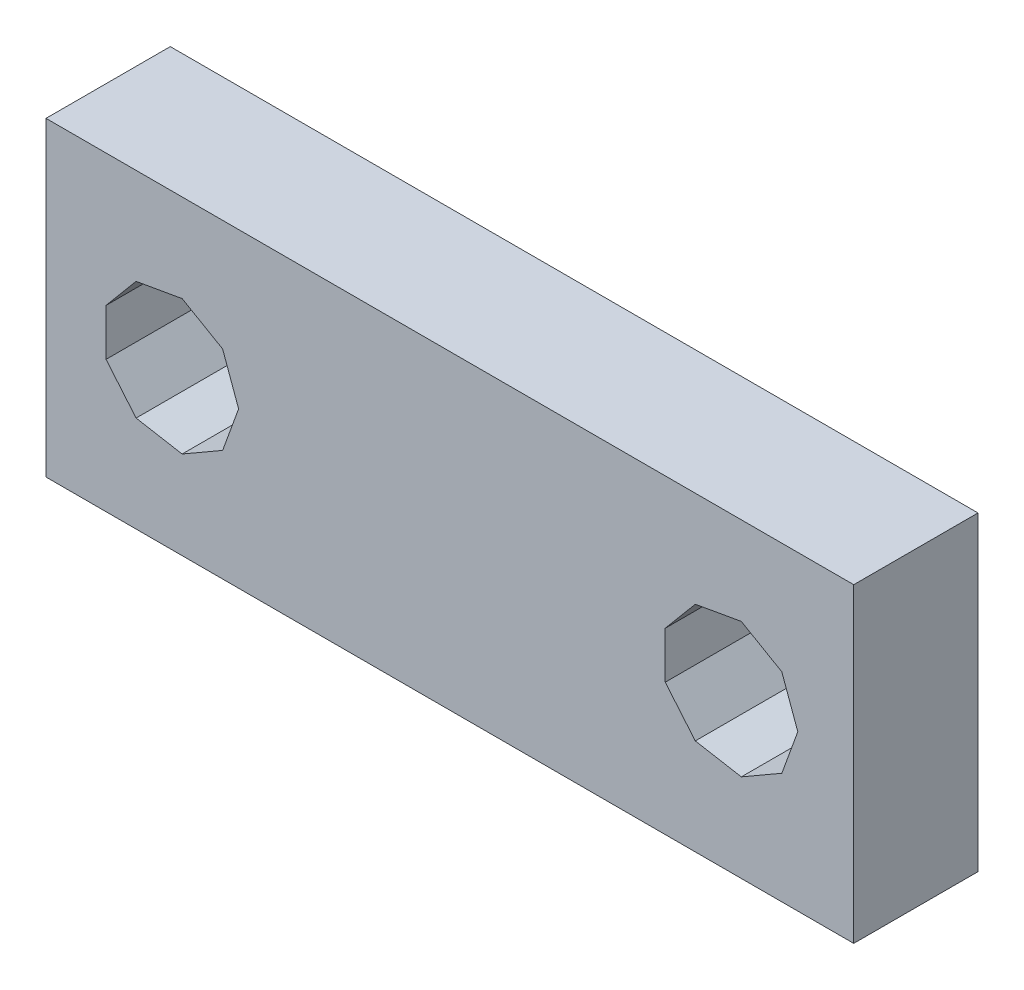
from build123d import *

# Parameters (mm, degrees)
SKETCH1_W           = 26
SKETCH1_H           = 10
BOSS_EXTRUDE1_DEPTH = 4


with BuildPart() as part:
    # Sketch1 → Boss-Extrude1 (new body)
    with BuildSketch(Plane.XY):
        with Locations((13, 5)):
            Rectangle(SKETCH1_W, SKETCH1_H)
        Polygon((2.899999851, 6.905256103), (4.382026, 7.166577107), (5.68529807, 6.414133033), (6.200000003, 5.000000051), (5.68529807, 3.585867069), (4.382026, 2.833422995), (2.899999851, 3.094743999), (1.932676008, 4.247555672), (1.932676008, 5.75244443), align=None, mode=Mode.SUBTRACT)
        Polygon((20.899999848, 6.905256103), (22.382025996, 7.166577107), (23.685298066, 6.414133033), (24.2, 5.000000051), (23.685298066, 3.585867069), (22.382025996, 2.833422995), (20.899999848, 3.094743999), (19.932676005, 4.247555672), (19.932676005, 5.75244443), align=None, mode=Mode.SUBTRACT)
    extrude(amount=BOSS_EXTRUDE1_DEPTH)


solid = part.part
